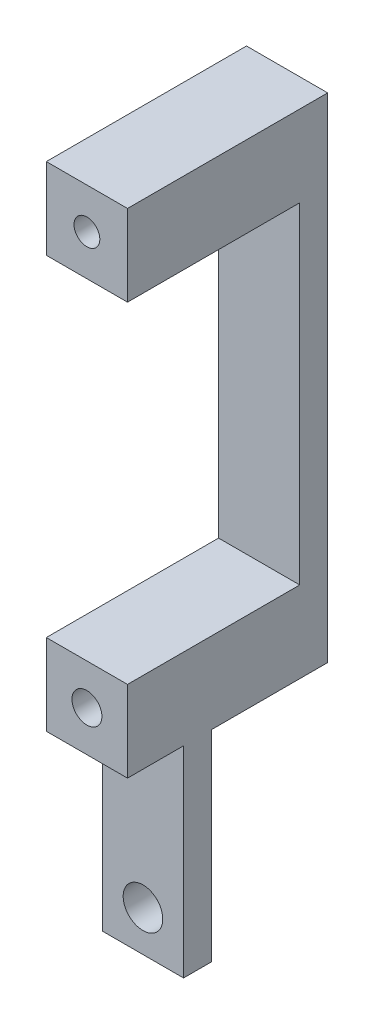
from build123d import *

# Parameters (mm, degrees)
SKETCH1_W           = 13.843
SKETCH1_H           = 48.133
BOSS_EXTRUDE1_DEPTH = 4.7625
SKETCH2_W           = 13.843
SKETCH2_H           = 13.843
BOSS_EXTRUDE2_DEPTH = 9.55675
SKETCH3_R           = 3.3782
CUT_EXTRUDE1_DEPTH  = 9.55675
SKETCH4_R           = 2.5527
CUT_EXTRUDE2_DEPTH  = 16.92275
SKETCH5_W           = 13.843
SKETCH5_H           = 13.843
BOSS_EXTRUDE3_DEPTH = 19.812
CUT_EXTRUDE3_DEPTH  = 19.812
SKETCH7_W           = 13.843
SKETCH7_H           = 4.7625
BOSS_EXTRUDE4_DEPTH = 70.2818
SKETCH8_W           = 13.843
SKETCH8_H           = 13.843
BOSS_EXTRUDE5_DEPTH = 29.36875
CUT_EXTRUDE4_DEPTH  = 7.62
SKETCH10_R          = 2.2
CUT_EXTRUDE5_DEPTH  = 27.51125


with BuildPart() as part:
    # Sketch1 → Boss-Extrude1 (new body)
    with BuildSketch(Plane.XY):
        with Locations((6.9215, 24.0665)):
            Rectangle(SKETCH1_W, SKETCH1_H)
    extrude(amount=BOSS_EXTRUDE1_DEPTH)

    # Sketch2 → Boss-Extrude2 (add)
    with BuildSketch(Plane.XY.offset(4.7625)):
        with Locations((6.9215, 41.2115)):
            Rectangle(SKETCH2_W, SKETCH2_H)
    extrude(amount=BOSS_EXTRUDE2_DEPTH)

    # Sketch3 → Cut-Extrude1 (cut)
    with BuildSketch(Plane(origin=(0, 0, 0), x_dir=(-1, 0, 0), z_dir=(0, 0, -1))):
        with Locations((-6.9215, 6.9215)):
            Circle(SKETCH3_R)
    extrude(amount=-CUT_EXTRUDE1_DEPTH, mode=Mode.SUBTRACT)

    # Sketch4 → Cut-Extrude2 (cut)
    with BuildSketch(Plane(origin=(0, 0, 0), x_dir=(-1, 0, 0), z_dir=(0, 0, -1))):
        with Locations((-6.9215, 41.2115)):
            Circle(SKETCH4_R)
    extrude(amount=-CUT_EXTRUDE2_DEPTH, mode=Mode.SUBTRACT)

    # Sketch5 → Boss-Extrude3 (add)
    with BuildSketch(Plane(origin=(0, 0, 0), x_dir=(-1, 0, 0), z_dir=(0, 0, -1))):
        with Locations((-6.9215, 41.2115)):
            Rectangle(SKETCH5_W, SKETCH5_H)
    extrude(amount=BOSS_EXTRUDE3_DEPTH)

    # Sketch6 → Cut-Extrude3 (cut)
    with BuildSketch(Plane(origin=(0, 0, -19.812), x_dir=(-1, 0, 0), z_dir=(0, 0, -1))):
        Polygon((-9.731894722, 46.082850851), (-12.545410948, 41.213302202), (-9.735016227, 36.341951351), (-4.111105278, 36.340149149), (-1.297589052, 41.209697798), (-4.107983773, 46.081048649), align=None)
    extrude(amount=-CUT_EXTRUDE3_DEPTH, mode=Mode.SUBTRACT)

    # Sketch7 → Boss-Extrude4 (add)
    with BuildSketch(Plane(origin=(0, 48.133, 0), x_dir=(1, 0, 0), z_dir=(0, 1, 0))):
        with Locations((6.9215, 17.43075)):
            Rectangle(SKETCH7_W, SKETCH7_H)
    extrude(amount=BOSS_EXTRUDE4_DEPTH)

    # Sketch8 → Boss-Extrude5 (add)
    with BuildSketch(Plane.XY.offset(-15.0495)):
        with Locations((6.9215, 111.4933)):
            Rectangle(SKETCH8_W, SKETCH8_H)
    extrude(amount=BOSS_EXTRUDE5_DEPTH)

    # Sketch9 → Cut-Extrude4 (cut)
    with BuildSketch(Plane(origin=(0, 0, -19.812), x_dir=(-1, 0, 0), z_dir=(0, 0, -1))):
        Polygon((-8.996554602, 115.0874), (-11.071609205, 111.4933), (-8.996554602, 107.8992), (-4.846445398, 107.8992), (-2.771390795, 111.4933), (-4.846445398, 115.0874), align=None)
    extrude(amount=-CUT_EXTRUDE4_DEPTH, mode=Mode.SUBTRACT)

    # Sketch10 → Cut-Extrude5 (cut, through all)
    with BuildSketch(Plane(origin=(0, 0, -12.192), x_dir=(-1, 0, 0), z_dir=(0, 0, -1))):
        with Locations((-6.9215, 111.4933)):
            Circle(SKETCH10_R)
    extrude(amount=-CUT_EXTRUDE5_DEPTH, mode=Mode.SUBTRACT)


solid = part.part
